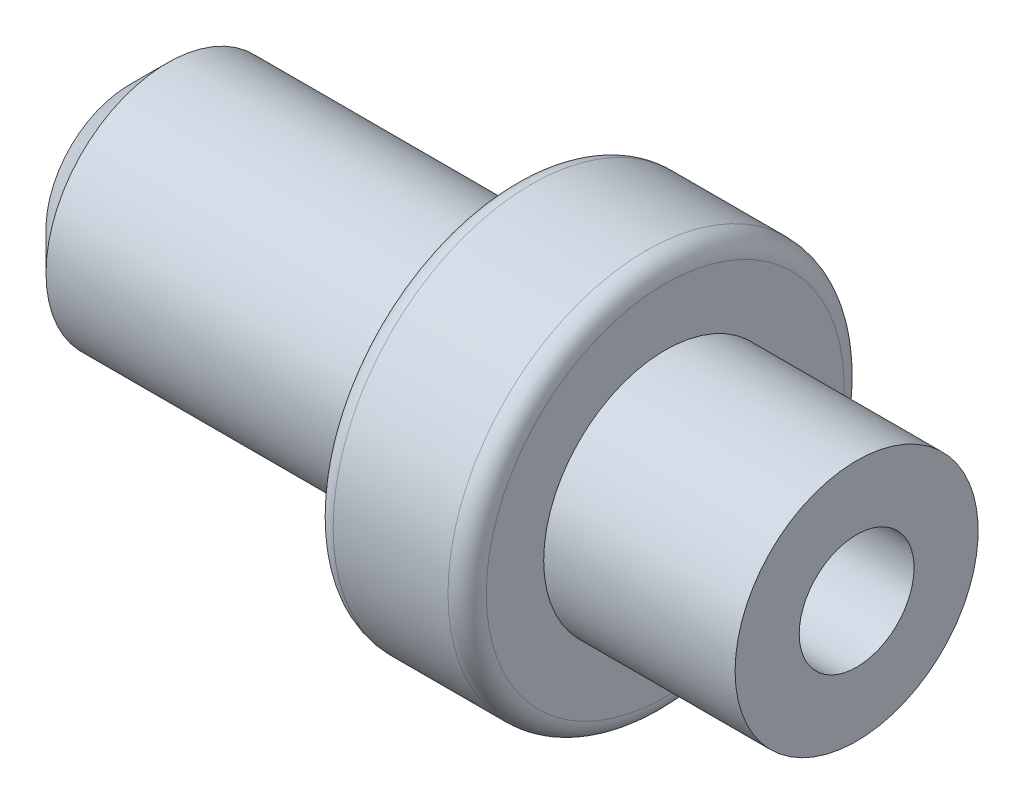
from build123d import *

# Parameters (mm, degrees)
CHAMFER1_SIZE = 1
FILLET1_R     = 0.5


with BuildPart() as part:
    # Sketch1 → Revolve1 (revolve)
    with BuildSketch(Plane.XY):
        Polygon((-10, 1.5), (-10, 3.175), (0, 3.175), (0, 5.175), (4, 5.175), (4, 3.175), (9, 3.175), (9, 1.5), align=None)
    revolve(axis=Axis((-34.824359623, 0, 0), (1, 0, 0)))

    # Chamfer1
    chamfer1_edges = [part.edges().sort_by_distance(p)[0] for p in [
        (-10, -3.175, 0),
    ]]
    chamfer(chamfer1_edges, length=CHAMFER1_SIZE)

    # Fillet1
    fillet1_edges = [part.edges().sort_by_distance(p)[0] for p in [
        (0, -5.175, 0),
        (4, -5.175, 0),
    ]]
    fillet(fillet1_edges, radius=FILLET1_R)


solid = part.part
